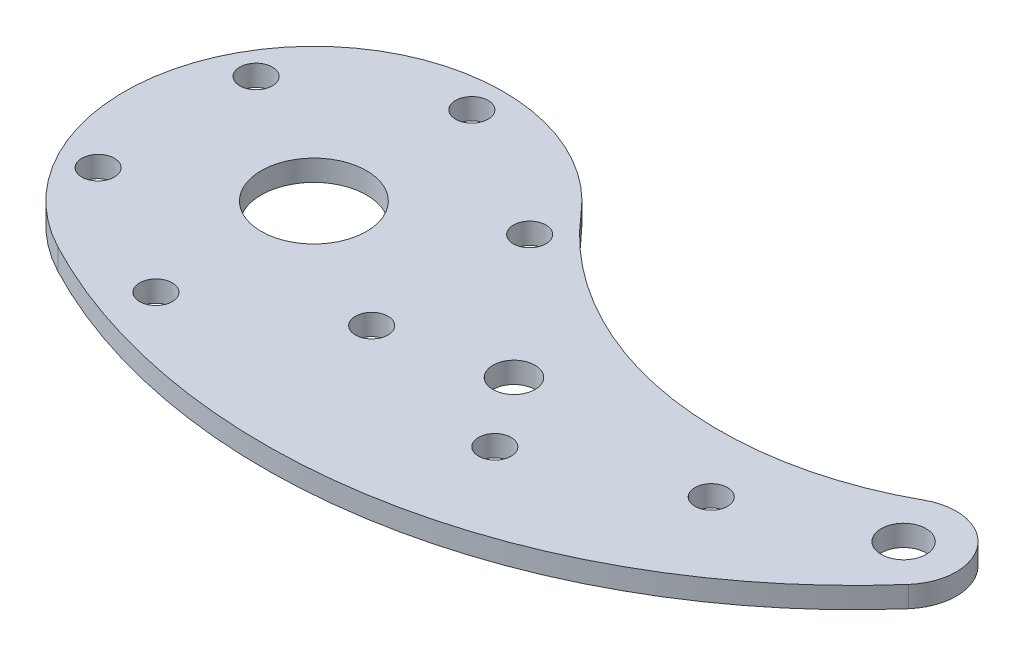
from build123d import *

# Parameters (mm, degrees)
SKETCH1_R                        = 7.9375
SKETCH1_R_2                      = 3.3782
BOSS_EXTRUDE1_DEPTH              = 3.175
F_10_0_1935_DIAMETER_HOLE1_D     = 4.9149
F_1_4_0_25_DIAMETER_HOLE2_D      = 6.35
F_10_0_1935_DIAMETER_HOLE2_D     = 4.9149
F_10_0_1935_DIAMETER_HOLE2_DEPTH = 12.0396
F_10_0_1935_DIAMETER_HOLE2_TIP   = 1.476584928


with BuildPart() as part:
    # Sketch1 → Boss-Extrude1 (new body)
    with BuildSketch(Plane(origin=(0, 0, 0), x_dir=(1, 0, 0), z_dir=(0, 1, 0))):
        with BuildLine():
            ThreePointArc((21.773129464, 18.505714208), (-22.309015306, 17.856048305), (-13.287106438, -25.297893737))
            ThreePointArc((-13.287106438, -25.297893737), (44.264595617, -34.002230789), (94.865631565, -5.235947505))
            ThreePointArc((94.865631565, -5.235947505), (95.083258514, 4.977069459), (85.059583132, 6.946589417))
            ThreePointArc((85.059583132, 6.946589417), (51.353410938, 1.431482164), (21.773129464, 18.505714208))
        make_face()
        Circle(SKETCH1_R, mode=Mode.SUBTRACT)
        with Locations((88.9, 0)):
            Circle(SKETCH1_R_2, mode=Mode.SUBTRACT)
    extrude(amount=BOSS_EXTRUDE1_DEPTH)

    # #10 (0.1935) Diameter Hole1 (through all)
    with Locations(Plane(origin=(0, 3.175, 0), x_dir=(1, 0, 0), z_dir=(0, 1, 0))):
        with Locations((0, -23.8125), (-20.622229928, 11.90625), (20.622229928, 11.90625), (20.622229928, -11.90625), (-20.622229928, -11.90625), (0, 23.8125)):
            Hole(F_10_0_1935_DIAMETER_HOLE1_D / 2)

    # 1/4 (0.25) Diameter Hole2 (through all)
    with Locations(Plane(origin=(0, 3.175, 0), x_dir=(1, 0, 0), z_dir=(0, 1, 0))):
        with Locations((38.1, -7.9375)):
            Hole(F_1_4_0_25_DIAMETER_HOLE2_D / 2)

    # #10 (0.1935) Diameter Hole2
    with Locations(Plane(origin=(0, 3.175, 0), x_dir=(1, 0, 0), z_dir=(0, 1, 0))):
        with Locations((68.58, -8.680112147), (45.72, -18.445238312)):
            Hole(F_10_0_1935_DIAMETER_HOLE2_D / 2, depth=F_10_0_1935_DIAMETER_HOLE2_DEPTH)
            with Locations((0, 0, -(F_10_0_1935_DIAMETER_HOLE2_DEPTH + F_10_0_1935_DIAMETER_HOLE2_TIP / 2))):  # 118° drill point
                Cone(0, F_10_0_1935_DIAMETER_HOLE2_D / 2, F_10_0_1935_DIAMETER_HOLE2_TIP, mode=Mode.SUBTRACT)


solid = part.part
